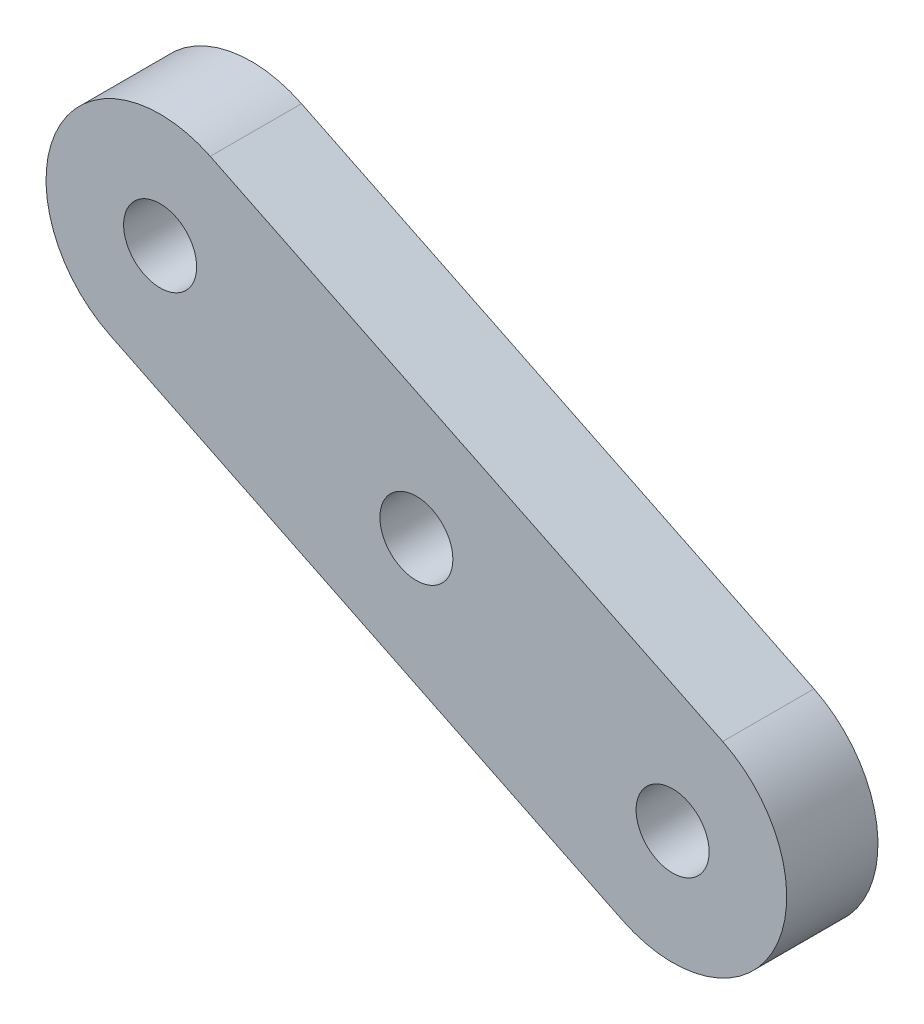
from build123d import *

# Parameters (mm, degrees)
SKETCH1_R           = 1.6
BOSS_EXTRUDE1_DEPTH = 4


with BuildPart() as part:
    # Sketch1 → Boss-Extrude1 (new body)
    with BuildSketch(Plane.XY):
        with BuildLine():
            Line((-2.195689363, -4.492098421), (-24.656181467, 6.486348392))
            ThreePointArc((-24.656181467, 6.486348392), (-26.952590525, 13.174136176), (-20.264802742, 15.470545234))
            Line((-20.264802742, 15.470545234), (2.195689363, 4.492098421))
            ThreePointArc((2.195689363, 4.492098421), (4.492098421, -2.195689363), (-2.195689363, -4.492098421))
        make_face()
        with Locations((-22.460492104, 10.978446813)):
            Circle(SKETCH1_R, mode=Mode.SUBTRACT)
        Circle(SKETCH1_R, mode=Mode.SUBTRACT)
        with Locations((-11.230246052, 5.489223407)):
            Circle(SKETCH1_R, mode=Mode.SUBTRACT)
    extrude(amount=BOSS_EXTRUDE1_DEPTH)


solid = part.part
